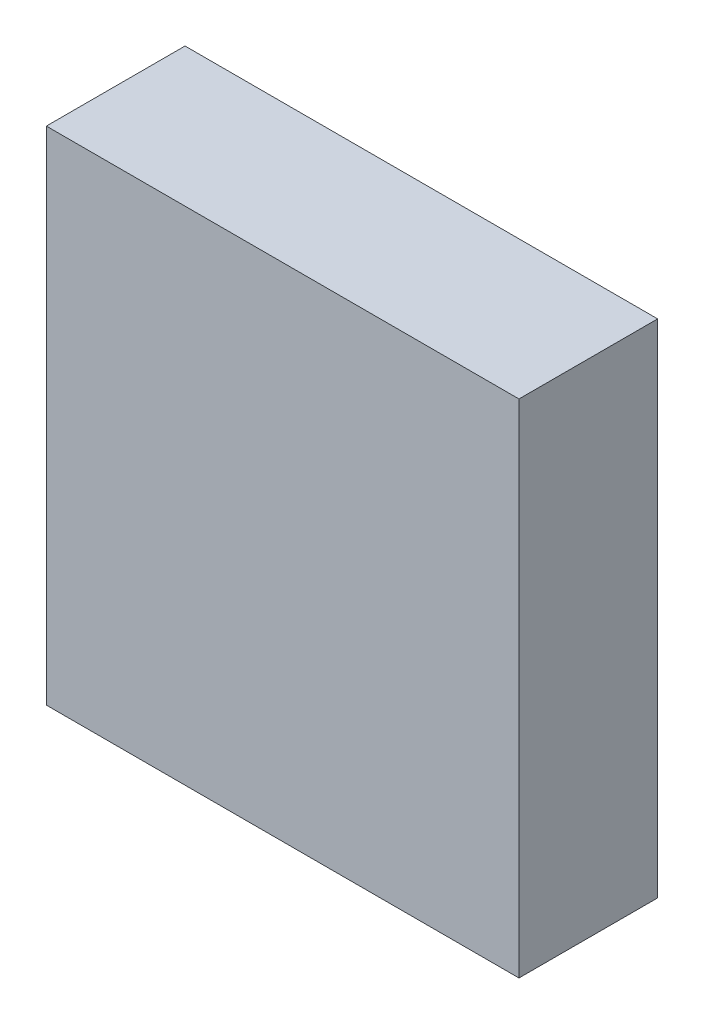
from build123d import *

# Parameters (mm, degrees)
SKETCH1_W               = 3.408
SKETCH1_H               = 3.616
COMPONENT_OUTLINE_DEPTH = 1


with BuildPart() as part:
    # Sketch1 → Component_Outline (new body)
    with BuildSketch(Plane.XY):
        Rectangle(SKETCH1_W, SKETCH1_H)
    extrude(amount=COMPONENT_OUTLINE_DEPTH)


solid = part.part
